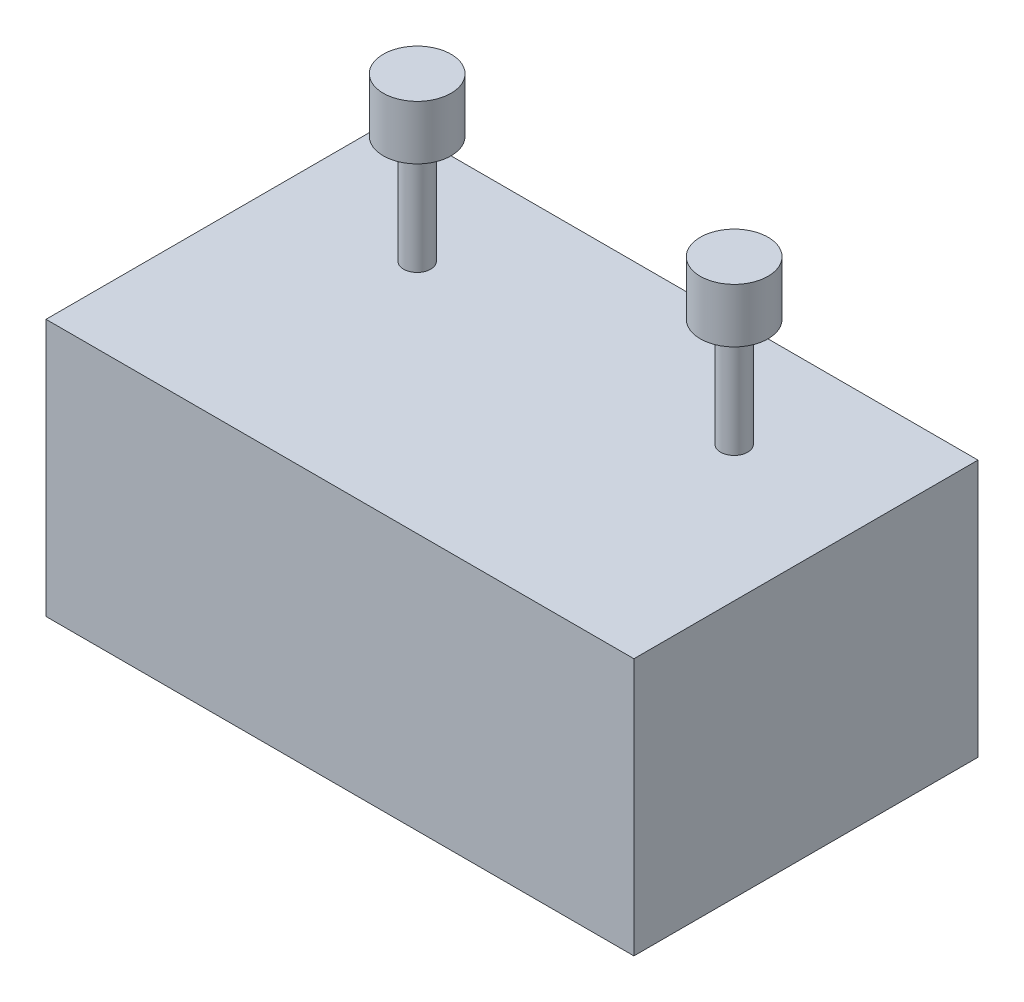
from build123d import *

# Parameters (mm, degrees)
SKETCH1_W           = 217
SKETCH1_H           = 127
BOSS_EXTRUDE1_DEPTH = 95
SKETCH2_R           = 5
BOSS_EXTRUDE2_DEPTH = 40
SKETCH3_R           = 12.5
BOSS_EXTRUDE3_DEPTH = 20


with BuildPart() as part:
    # Sketch1 → Boss-Extrude1 (new body)
    with BuildSketch(Plane(origin=(0, 0, 0), x_dir=(1, 0, 0), z_dir=(0, 1, 0))):
        Rectangle(SKETCH1_W, SKETCH1_H)
    extrude(amount=BOSS_EXTRUDE1_DEPTH)

    # Sketch2 → Boss-Extrude2 (add)
    with BuildSketch(Plane(origin=(0, 95, 0), x_dir=(1, 0, 0), z_dir=(0, 1, 0))):
        with Locations((-58.5, 23.5)):
            Circle(SKETCH2_R)
        with Locations((58.5, 23.5)):
            Circle(SKETCH2_R)
    extrude(amount=BOSS_EXTRUDE2_DEPTH)

    # Sketch3 → Boss-Extrude3 (add)
    with BuildSketch(Plane(origin=(0, 135, 0), x_dir=(1, 0, 0), z_dir=(0, 1, 0))):
        with Locations((-58.5, 23.5)):
            Circle(SKETCH3_R)
        with Locations((58.5, 23.5)):
            Circle(SKETCH3_R)
    extrude(amount=BOSS_EXTRUDE3_DEPTH)


solid = part.part
